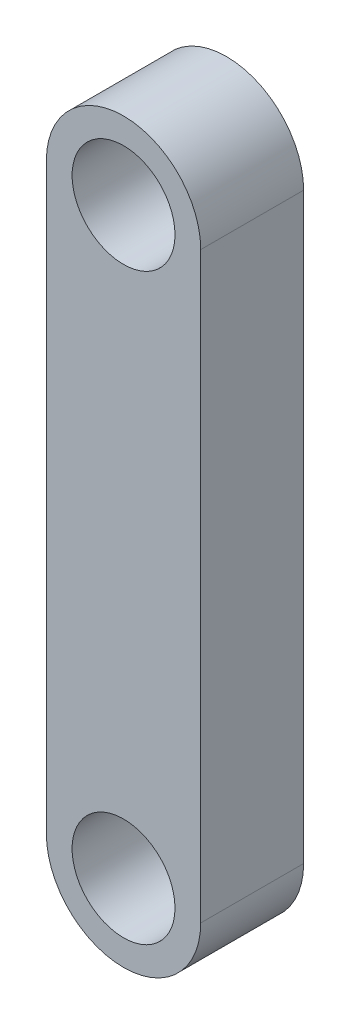
from build123d import *

# Parameters (mm, degrees)
MODEL_R             = 1.500000002
BOSS_EXTRUDE1_DEPTH = 3


with BuildPart() as part:
    # Model → Boss-Extrude1 (new body)
    with BuildSketch(Plane.XY):
        with BuildLine():
            Line((67.75, 48.499971421), (67.75, 31.499971421))
            ThreePointArc((67.75, 31.499971421), (69.999999998, 29.249971421), (72.25, 31.499971421))
            Line((72.25, 31.499971421), (72.25, 48.499971421))
            ThreePointArc((72.25, 48.499971421), (69.999999998, 50.749971421), (67.75, 48.499971421))
        make_face()
        with Locations((69.999999998, 48.499971419)):
            Circle(MODEL_R, mode=Mode.SUBTRACT)
        with Locations((69.999999998, 31.499971419)):
            Circle(MODEL_R, mode=Mode.SUBTRACT)
    extrude(amount=BOSS_EXTRUDE1_DEPTH)


solid = part.part
